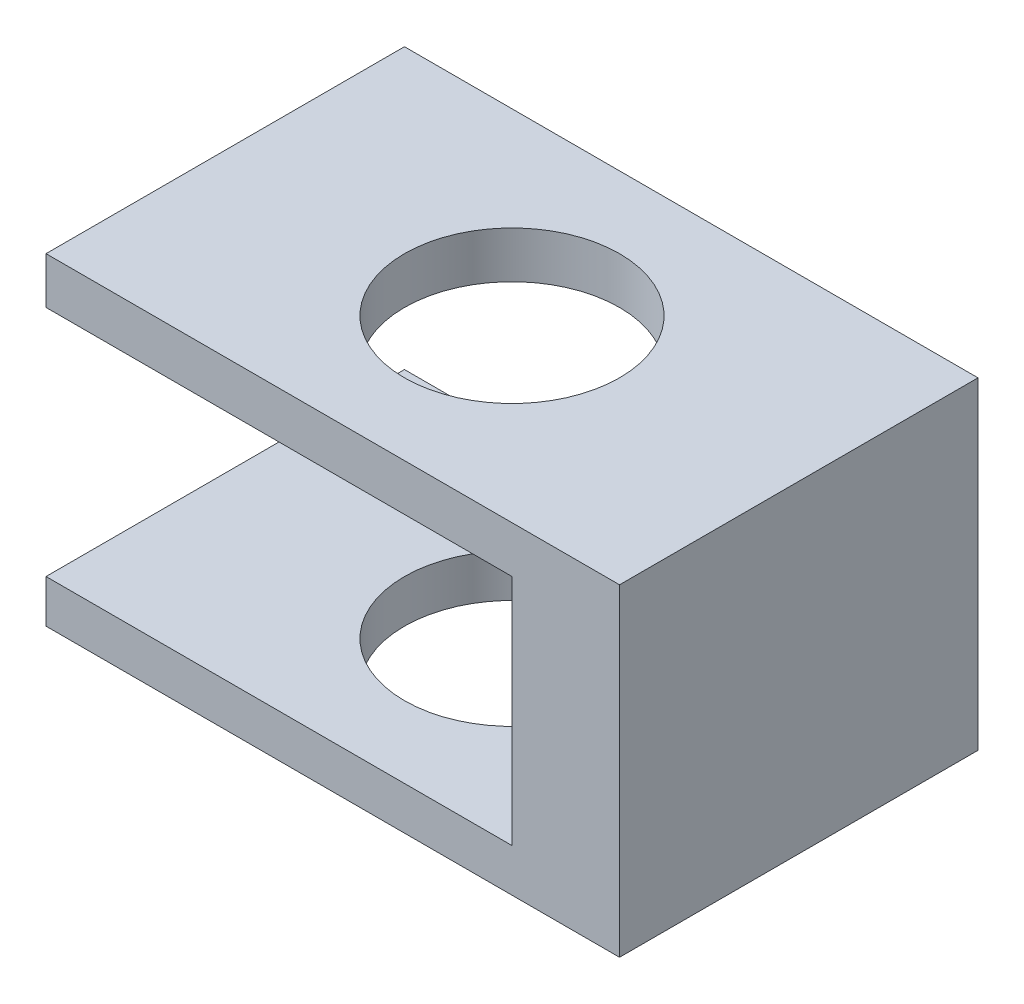
from build123d import *

# Parameters (mm, degrees)
SKETCH2_W           = 1.6
SKETCH2_H           = 0.9
BOSS_EXTRUDE2_DEPTH = 1
SKETCH5_R           = 0.3
CUT_EXTRUDE2_DEPTH  = 1
SKETCH6_W           = 1
SKETCH6_H           = 0.65
CUT_EXTRUDE3_DEPTH  = 0.8
SKETCH7_W           = 1.3
SKETCH7_H           = 0.65
CUT_EXTRUDE4_DEPTH  = 1


with BuildPart() as part:
    # Sketch2 → Boss-Extrude2 (new body)
    with BuildSketch(Plane.XY):
        Rectangle(SKETCH2_W, SKETCH2_H)
    extrude(amount=BOSS_EXTRUDE2_DEPTH)

    # Sketch5 → Cut-Extrude2 (cut)
    with BuildSketch(Plane(origin=(0, 0.45, 0), x_dir=(1, 0, 0), z_dir=(0, 1, 0))):
        with Locations((0, -0.5)):
            Circle(SKETCH5_R)
    extrude(amount=-CUT_EXTRUDE2_DEPTH, mode=Mode.SUBTRACT)

    # Sketch6 → Cut-Extrude3 (cut)
    with BuildSketch(Plane.XY.offset(1)):
        with Locations((0, -0.005)):
            Rectangle(SKETCH6_W, SKETCH6_H)
    extrude(amount=-CUT_EXTRUDE3_DEPTH, mode=Mode.SUBTRACT)

    # Sketch7 → Cut-Extrude4 (cut)
    with BuildSketch(Plane.XY.offset(1)):
        with Locations((-0.15, -0.005)):
            Rectangle(SKETCH7_W, SKETCH7_H)
    extrude(amount=-CUT_EXTRUDE4_DEPTH, mode=Mode.SUBTRACT)


solid = part.part
